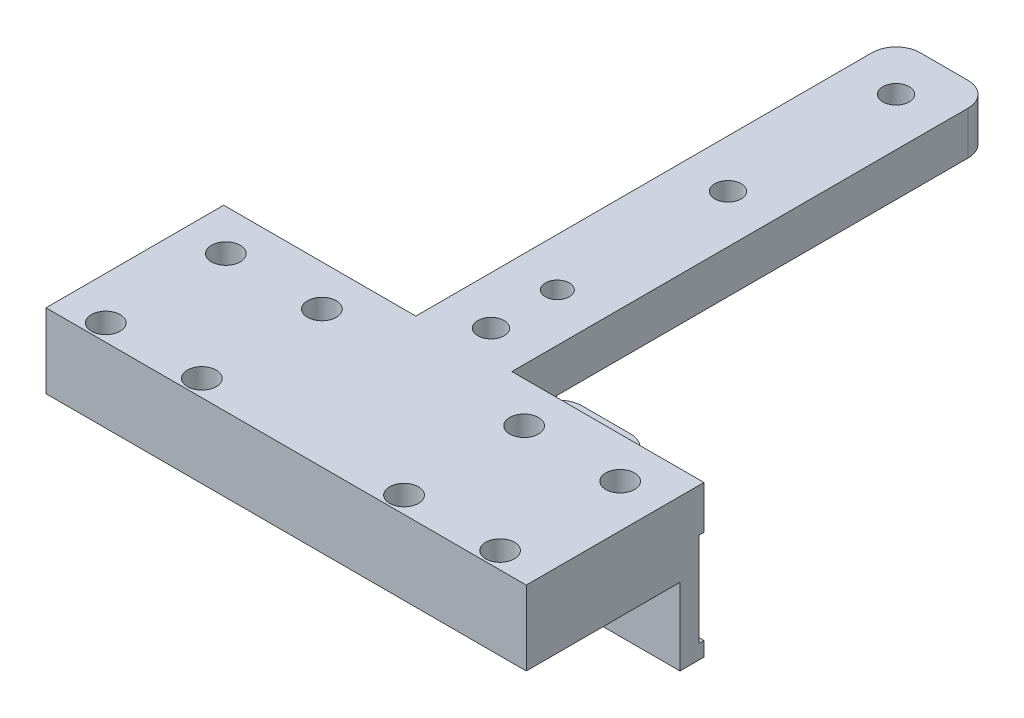
from build123d import *

# Parameters (mm, degrees)
SKETCH1_W                      = 100
SKETCH1_H                      = 37
BOSS_EXTRUDE1_DEPTH            = 6
M3_CLEARANCE_HOLE1_D           = 3.4
SKETCH31_W                     = 20
SKETCH31_H                     = 29.63
BOSS_EXTRUDE9_DEPTH            = 16
BOSS_EXTRUDE9_DEPTH_BACK       = 9
SKETCH32_W                     = 100
SKETCH32_H                     = 5
BOSS_EXTRUDE10_DEPTH           = 16
SKETCH33_R                     = 3
BOSS_EXTRUDE11_DEPTH           = 3
SKETCH34_W                     = 3
SKETCH34_H                     = 19.5
CUT_EXTRUDE1_DEPTH             = 101
CUT_EXTRUDE2_START             = -2.5
SKETCH35_W                     = 20
SKETCH35_H                     = 20.32
CUT_EXTRUDE2_DEPTH             = 19.5
SKETCH36_R                     = 2.5
CUT_EXTRUDE3_DEPTH             = 26
FILLET1_R                      = 5
SKETCH37_R                     = 3
SKETCH37_R_2                   = 2.5
BOSS_EXTRUDE12_DEPTH           = 6.5
BOSS_EXTRUDE12_DEPTH_BACK      = 2.5
CBORE_FOR_M5_SHCS1_D           = 5.5
CBORE_FOR_M5_SHCS1_CBORE_D     = 10
CBORE_FOR_M5_SHCS1_CBORE_DEPTH = 26
M5_CLEARANCE_HOLE1_D           = 5.5
FILLET3_R                      = 5
SKETCH48_W                     = 11.20158878
SKETCH48_H                     = 10
BOSS_EXTRUDE15_DEPTH           = 14


with BuildPart() as part:
    # Sketch1 → Boss-Extrude1 (new body)
    with BuildSketch(Plane(origin=(0, 0, 0), x_dir=(1, 0, 0), z_dir=(0, 1, 0))):
        with Locations((50, 18.5)):
            Rectangle(SKETCH1_W, SKETCH1_H)
    extrude(amount=BOSS_EXTRUDE1_DEPTH)

    # M3 Clearance Hole1 (through all)
    with Locations(Plane(origin=(0, 0, 0), x_dir=(-1, 0, 0), z_dir=(0, -1, 0))):
        with Locations((-8.95, 3.5), (-8.95, 28.5), (-28.95, 28.5), (-28.95, 3.5), (-71.05, 3.5), (-71.05, 28.5), (-91.05, 28.5), (-91.05, 3.5)):
            Hole(M3_CLEARANCE_HOLE1_D / 2)

    # Sketch31 → Boss-Extrude9 (add, two sides)
    with BuildSketch(Plane.XZ) as boss_extrude9_sk:
        with Locations((50, -51.815)):
            Rectangle(SKETCH31_W, SKETCH31_H)
    extrude(amount=BOSS_EXTRUDE9_DEPTH)
    extrude(boss_extrude9_sk.sketch, amount=-BOSS_EXTRUDE9_DEPTH_BACK)

    # Sketch32 → Boss-Extrude10 (add)
    with BuildSketch(Plane.XZ):
        with Locations((50, -34.5)):
            Rectangle(SKETCH32_W, SKETCH32_H)
    extrude(amount=BOSS_EXTRUDE10_DEPTH)

    # Sketch33 → Boss-Extrude11 (add)
    with BuildSketch(Plane(origin=(0, 6, 0), x_dir=(1, 0, 0), z_dir=(0, 1, 0))):
        Polygon((0, 37), (0, 0), (100, 0), (100, 37), (60, 37), (40, 37), align=None)
        with Locations((71.05, 3.5)):
            Circle(SKETCH33_R, mode=Mode.SUBTRACT)
        with Locations((71.05, 28.5)):
            Circle(SKETCH33_R, mode=Mode.SUBTRACT)
        with Locations((28.95, 3.5)):
            Circle(SKETCH33_R, mode=Mode.SUBTRACT)
        with Locations((28.95, 28.5)):
            Circle(SKETCH33_R, mode=Mode.SUBTRACT)
        with Locations((8.95, 28.5)):
            Circle(SKETCH33_R, mode=Mode.SUBTRACT)
        with Locations((8.95, 3.5)):
            Circle(SKETCH33_R, mode=Mode.SUBTRACT)
        with Locations((91.05, 3.5)):
            Circle(SKETCH33_R, mode=Mode.SUBTRACT)
        with Locations((91.05, 28.5)):
            Circle(SKETCH33_R, mode=Mode.SUBTRACT)
    extrude(amount=BOSS_EXTRUDE11_DEPTH)

    # Sketch34 → Cut-Extrude1 (cut, through all)
    with BuildSketch(Plane(origin=(100, 0, 0), x_dir=(0, 0, -1), z_dir=(1, 0, 0))):
        with Locations((37.5, -3.25)):
            Rectangle(SKETCH34_W, SKETCH34_H)
    extrude(amount=-CUT_EXTRUDE1_DEPTH, mode=Mode.SUBTRACT)

    # Sketch35 → Cut-Extrude2 (cut)
    with BuildSketch(Plane(origin=(0, 9, 0), x_dir=(1, 0, 0), z_dir=(0, 1, 0)).offset(CUT_EXTRUDE2_START)):
        with Locations((50, 56.47)):
            Rectangle(SKETCH35_W, SKETCH35_H)
    extrude(amount=-CUT_EXTRUDE2_DEPTH, mode=Mode.SUBTRACT)

    # Sketch36 → Cut-Extrude3 (cut, through all)
    with BuildSketch(Plane(origin=(0, 9, 0), x_dir=(1, 0, 0), z_dir=(0, 1, 0))):
        with Locations((50, 56.47)):
            Circle(SKETCH36_R)
    extrude(amount=-CUT_EXTRUDE3_DEPTH, mode=Mode.SUBTRACT)

    # Fillet1
    fillet1_edges = [part.edges().sort_by_distance(p)[0] for p in [
        (60, 7.75, -66.63),
        (40, 7.75, -66.63),
        (40, -14.5, -66.63),
        (60, -14.5, -66.63),
    ]]
    fillet(fillet1_edges, radius=FILLET1_R)

    # Sketch37 → Boss-Extrude12 (add, two sides)
    with BuildSketch(Plane(origin=(0, 9, 0), x_dir=(1, 0, 0), z_dir=(0, 1, 0))) as boss_extrude12_sk:
        Polygon((40, 37), (0, 37), (0, 0), (100, 0), (100, 37), (60, 37), (60, 137), (40, 137), align=None)
        with Locations((28.95, 3.5)):
            Circle(SKETCH37_R, mode=Mode.SUBTRACT)
        with Locations((8.95, 3.5)):
            Circle(SKETCH37_R, mode=Mode.SUBTRACT)
        with Locations((8.95, 28.5)):
            Circle(SKETCH37_R, mode=Mode.SUBTRACT)
        with Locations((28.95, 28.5)):
            Circle(SKETCH37_R, mode=Mode.SUBTRACT)
        with Locations((71.05, 28.5)):
            Circle(SKETCH37_R, mode=Mode.SUBTRACT)
        with Locations((91.05, 28.5)):
            Circle(SKETCH37_R, mode=Mode.SUBTRACT)
        with Locations((91.05, 3.5)):
            Circle(SKETCH37_R, mode=Mode.SUBTRACT)
        with Locations((71.05, 3.5)):
            Circle(SKETCH37_R, mode=Mode.SUBTRACT)
        with Locations((50, 56.47)):
            Circle(SKETCH37_R_2, mode=Mode.SUBTRACT)
    extrude(amount=BOSS_EXTRUDE12_DEPTH)
    extrude(boss_extrude12_sk.sketch, amount=-BOSS_EXTRUDE12_DEPTH_BACK)

    # CBORE for M5 SHCS1 (through all)
    with Locations(Plane(origin=(0, -16, 0), x_dir=(-1, 0, 0), z_dir=(0, -1, 0))):
        with Locations((-50, 127), (-50, 92)):
            CounterBoreHole(CBORE_FOR_M5_SHCS1_D / 2, CBORE_FOR_M5_SHCS1_CBORE_D / 2, CBORE_FOR_M5_SHCS1_CBORE_DEPTH)

    # M5 Clearance Hole1 (through all)
    with Locations(Plane(origin=(0, -16, 0), x_dir=(-1, 0, 0), z_dir=(0, -1, 0))):
        with Locations((-50, 42.655)):
            Hole(M5_CLEARANCE_HOLE1_D / 2)

    # Fillet3
    fillet3_edges = [part.edges().sort_by_distance(p)[0] for p in [
        (60, 11, -137),
        (40, 11, -137),
    ]]
    fillet(fillet3_edges, radius=FILLET3_R)

    # Sketch48 → Boss-Extrude15 (add)
    with BuildSketch(Plane.XZ):
        with Locations((50, -31)):
            Rectangle(SKETCH48_W, SKETCH48_H)
    extrude(amount=BOSS_EXTRUDE15_DEPTH)


solid = part.part
